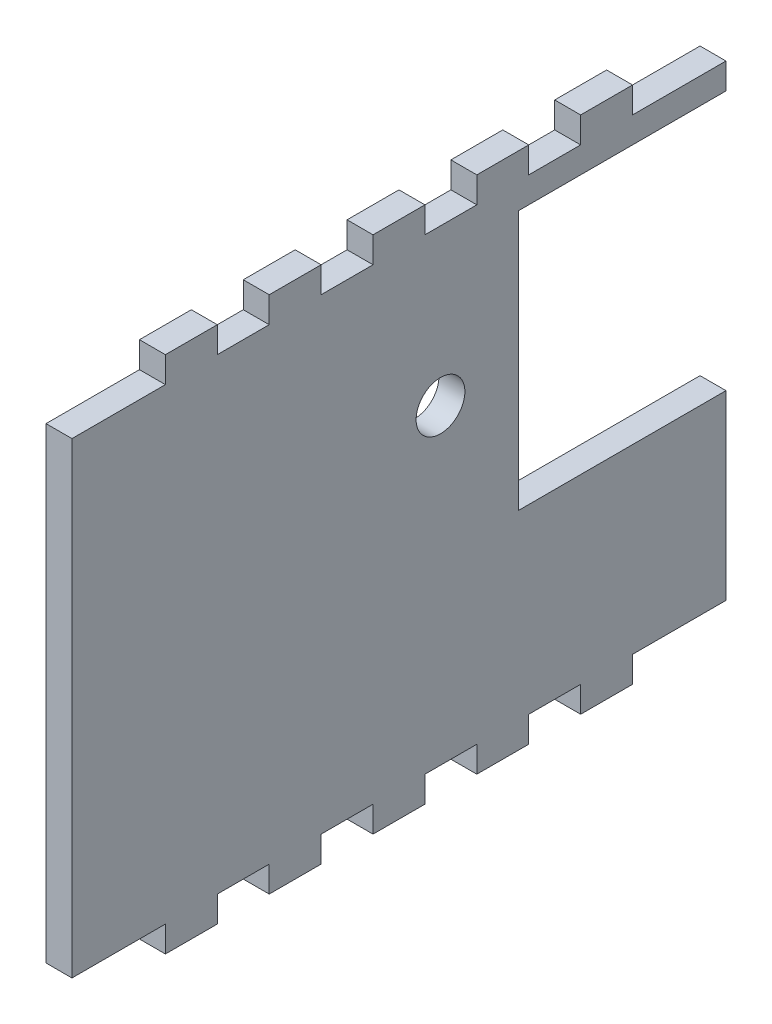
from build123d import *

# Parameters (mm, degrees)
SKETCH2_W           = 80.01
SKETCH2_H           = 63.5
BOSS_EXTRUDE1_DEPTH = 3.175
SKETCH3_W           = 11.43
SKETCH3_H           = 3.175
SKETCH3_W_2         = 6.35
CUT_EXTRUDE1_DEPTH  = 4.175
SKETCH4_R           = 2.9845
SKETCH4_W           = 25.4
SKETCH4_H           = 31.75
CUT_EXTRUDE2_DEPTH  = 4.175


with BuildPart() as part:
    # Sketch2 → Boss-Extrude1 (new body)
    with BuildSketch(Plane(origin=(0, 0, 0), x_dir=(0, 0, -1), z_dir=(1, 0, 0))):
        Rectangle(SKETCH2_W, SKETCH2_H)
    extrude(amount=BOSS_EXTRUDE1_DEPTH)

    # Sketch3 → Cut-Extrude1 (cut, through all)
    with BuildSketch(Plane.ZY):
        with Locations((-34.29, -30.1625)):
            Rectangle(SKETCH3_W, SKETCH3_H)
        with Locations((-19.05, -30.1625)):
            Rectangle(SKETCH3_W_2, SKETCH3_H)
        with Locations((-6.35, -30.1625)):
            Rectangle(SKETCH3_W_2, SKETCH3_H)
        with Locations((6.35, -30.1625)):
            Rectangle(SKETCH3_W_2, SKETCH3_H)
        with Locations((19.05, -30.1625)):
            Rectangle(SKETCH3_W_2, SKETCH3_H)
        with Locations((34.29, -30.1625)):
            Rectangle(SKETCH3_W, SKETCH3_H)
        with Locations((34.29, 30.1625)):
            Rectangle(SKETCH3_W, SKETCH3_H)
        with Locations((19.05, 30.1625)):
            Rectangle(SKETCH3_W_2, SKETCH3_H)
        with Locations((6.35, 30.1625)):
            Rectangle(SKETCH3_W_2, SKETCH3_H)
        with Locations((-6.35, 30.1625)):
            Rectangle(SKETCH3_W_2, SKETCH3_H)
        with Locations((-19.05, 30.1625)):
            Rectangle(SKETCH3_W_2, SKETCH3_H)
        with Locations((-34.29, 30.1625)):
            Rectangle(SKETCH3_W, SKETCH3_H)
    extrude(amount=-CUT_EXTRUDE1_DEPTH, mode=Mode.SUBTRACT)

    # Sketch4 → Cut-Extrude2 (cut, through all)
    with BuildSketch(Plane(origin=(3.175, 0, 0), x_dir=(0, 0, -1), z_dir=(1, 0, 0))):
        with Locations((5.08, 9.525)):
            Circle(SKETCH4_R)
        with Locations((27.305, 9.525)):
            Rectangle(SKETCH4_W, SKETCH4_H)
    extrude(amount=-CUT_EXTRUDE2_DEPTH, mode=Mode.SUBTRACT)


solid = part.part
